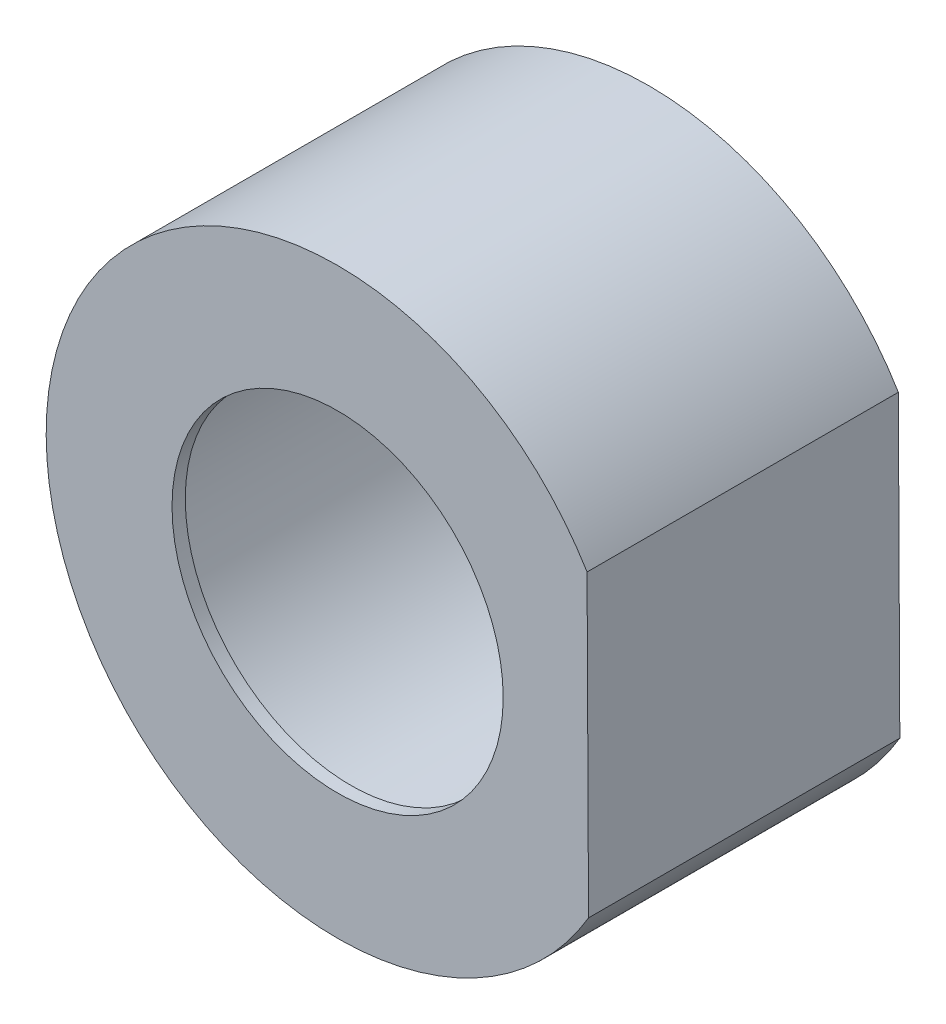
from build123d import *

# Parameters (mm, degrees)
EXTRUDE_1_DEPTH     = 23.5
SKETCH_6_R          = 16
CUT_EXTRUDE_8_DEPTH = 22.5
SKETCH_7_R          = 12.5
CUT_EXTRUDE_9_DEPTH = 2


with BuildPart() as part:
    # Эскиз1 → Вытянуть1 (new body)
    with BuildSketch(Plane.XY):
        with BuildLine():
            Line((18.943049375, -11.187532363), (18.832657697, 11.372378998))
            ThreePointArc((18.832657697, 11.372378998), (-21.99973662, -0.107650593), (18.943049375, -11.187532363))
        make_face()
    extrude(amount=EXTRUDE_1_DEPTH)

    # Эскиз6 → Вытянуть8 (cut)
    with BuildSketch(Plane(origin=(0, 0, 0), x_dir=(-1, 0, 0), z_dir=(0, 0, -1))):
        Circle(SKETCH_6_R)
    extrude(amount=-CUT_EXTRUDE_8_DEPTH, mode=Mode.SUBTRACT)

    # Эскиз7 → Вытянуть9 (cut, through all)
    with BuildSketch(Plane(origin=(0, 0, 22.5), x_dir=(-1, 0, 0), z_dir=(0, 0, -1))):
        Circle(SKETCH_7_R)
    extrude(amount=-CUT_EXTRUDE_9_DEPTH, mode=Mode.SUBTRACT)


solid = part.part
